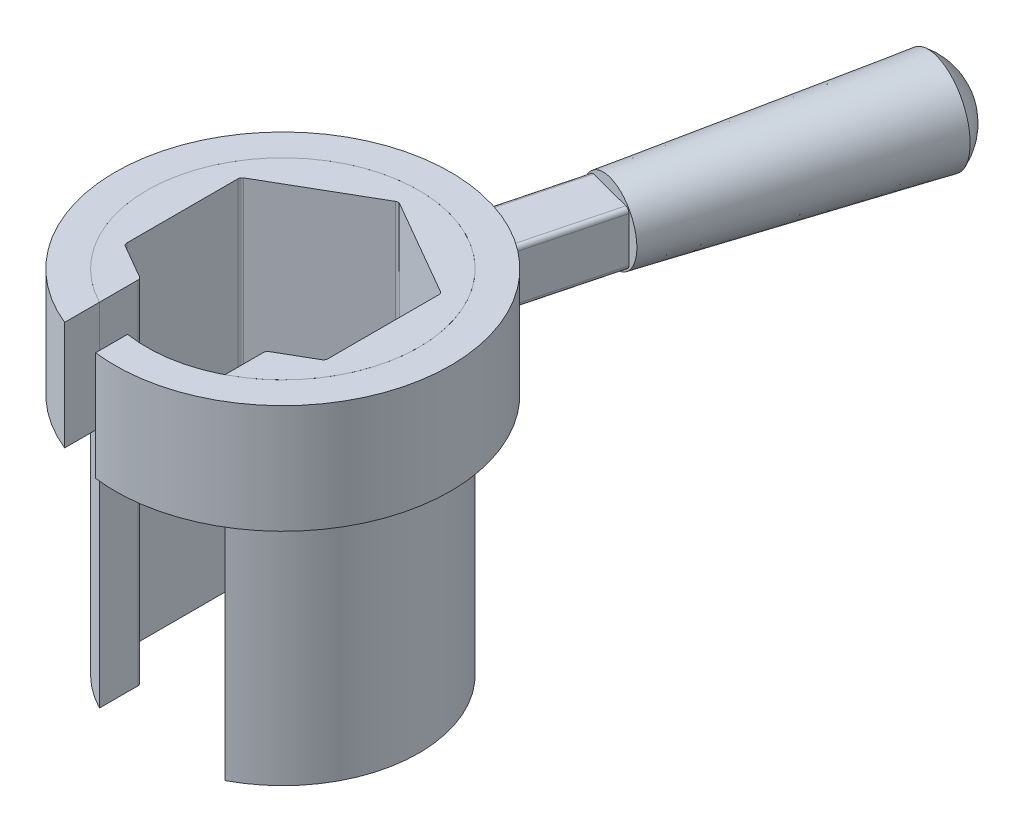
from build123d import *

# Parameters (mm, degrees)
EXTRUDE3_DEPTH                  = 42
EXTRUDE4_DEPTH                  = 13
SKETCH22_W                      = 6.4
SKETCH22_H                      = 6.4
EXTRUDE5_DEPTH                  = 12
EXTRUDE5_DIRECTION_2_REACH      = 64.818
EXTRUDE5_DIRECTION_2_END_RADIUS = 20.03
SKETCH23_R                      = 4.5254834
EXTRUDE6_DEPTH                  = 32
EXTRUDE6_DRAFT                  = -2
DOME1_FACE_RADIUS               = 5.642948023
DOME1_HEIGHT                    = 3
CUT_EXTRUDE7_DEPTH              = 81.414359668
FILLET2_R                       = 0.5
FILLET3_R                       = 0.5


with BuildPart() as part:
    # Sketch20 → Extrude3 (new body)
    with BuildSketch(Plane(origin=(0, 0, 0), x_dir=(1, 0, 0), z_dir=(0, 1, 0))):
        with BuildLine():
            Line((-7.5, -9.367496998), (-7.5, -14.415703243))
            ThreePointArc((-7.5, -14.415703243), (0, 16.25), (7.5, -14.415703243))
            Line((7.5, -14.415703243), (7.5, -9.367496998))
            ThreePointArc((7.5, -9.367496998), (0, 12), (-7.5, -9.367496998))
        make_face()
    extrude(amount=EXTRUDE3_DEPTH)

    # Sketch24 → Cut-Extrude7 (cut, through all)
    with BuildSketch(Plane.XZ):
        Polygon((-12, 6.92820323), (-12, -6.92820323), (0, -13.856406461), (12, -6.92820323), (12, 6.92820323), (0, 13.856406461), align=None)
    extrude(amount=-CUT_EXTRUDE7_DEPTH, mode=Mode.SUBTRACT)

    # Fillet3
    fillet3_edges = [part.edges().sort_by_distance(p)[0] for p in [
        (-7.5, 21, 9.526279442),
        (-12, 21, 6.92820323),
        (7.5, 21, 9.526279442),
        (12, 21, 6.92820323),
        (12, 21, -6.92820323),
        (0, 21, -13.856406461),
        (-12, 21, -6.92820323),
    ]]
    fillet(fillet3_edges, radius=FILLET3_R)


with BuildPart() as body_2:
    # Sketch21 → Extrude4 (new body)
    with BuildSketch(Plane(origin=(0, 41.999, 0), x_dir=(-1, 0, 0), z_dir=(0, 1, 0))):
        with BuildLine():
            Line((2.5, 16.056540723), (2.5, 19.873371631))
            ThreePointArc((2.5, 19.873371631), (-5.042106368, -19.384995831), (7.5, 18.572853846))
            Line((7.5, 18.572853846), (7.5, 14.415703243))
            ThreePointArc((7.5, 14.415703243), (-5.066861643, -15.439864413), (2.5, 16.056540723))
        make_face()
    extrude(amount=-EXTRUDE4_DEPTH)


with BuildPart() as body_3:
    # Sketch22 → Extrude5 (new body)
    with BuildSketch(Plane(origin=(5.042106368, 41.999, -19.384995831), x_dir=(-0.9677980944146168, 0, -0.2517277268149784), z_dir=(0.2517277268149784, 0, -0.9677980944146168))):
        with Locations((0, -6.5)):
            Rectangle(SKETCH22_W, SKETCH22_H)
    extrude(amount=EXTRUDE5_DEPTH)

    # Extrude5 direction 2: up to this cylinder (the profile starts outside it)
    extrude5_direction_2_end = Plane(origin=(0, 35.499, 0), z_dir=(0, 1, 0)) * Cylinder(EXTRUDE5_DIRECTION_2_END_RADIUS, 170.696, mode=Mode.PRIVATE)
    # Sketch22 → Extrude5 direction 2 (add, up to the surface)
    with BuildSketch(Plane(origin=(5.042106368, 41.999, -19.384995831), x_dir=(-0.9677980944146168, 0, -0.2517277268149784), z_dir=(0.2517277268149784, 0, -0.9677980944146168)), mode=Mode.PRIVATE) as extrude5_direction_2_sk1:
        with Locations((0, -6.5)):
            Rectangle(SKETCH22_W, SKETCH22_H)
    extrude5_direction_2_tool1 = extrude(extrude5_direction_2_sk1.sketch, amount=-EXTRUDE5_DIRECTION_2_REACH, mode=Mode.PRIVATE) - extrude5_direction_2_end
    add(extrude5_direction_2_tool1.solids().sort_by_distance((5.042106, 35.499, -19.384996))[0])
    add(extrude5_direction_2_tool1.solids().sort_by_distance((5.042106, 35.499, -19.384996))[1])


with BuildPart() as extrude6_tool:
    # Sketch23 → Extrude6 (with draft: the straight prism first)
    with BuildSketch(Plane(origin=(8.06283909, 0, -30.998572964), x_dir=(-0.9677980944146167, -1.6827536930173812e-15, -0.25172772681497885), z_dir=(0.25172772681497885, 0, -0.9677980944146167))):
        with Locations((0, 35.499)):
            Circle(SKETCH23_R)
    extrude(amount=EXTRUDE6_DEPTH)
    # Extrude6: the draft: its side faces are tilted about the plane it starts from
    extrude6_sides = [extrude6_tool.faces().sort_by_distance(p)[0] for p in [
        (16.470236929, 35.499, -45.344152826),
    ]]
    draft(extrude6_sides, Plane(origin=(8.06283909, 0, -30.998572964), x_dir=(-0.9677980944146167, -1.6827536930173812e-15, -0.25172772681497885), z_dir=(0.25172772681497885, 0, -0.9677980944146167)), EXTRUDE6_DRAFT)


with BuildPart() as body_3_1:
    add(body_3.part)

    # Extrude6: add extrude6_tool
    add(extrude6_tool.part)

    # Dome1: a dome of height H over a round flat face of radius A is a cap of a sphere of radius (A * A + H * H) / (2 * H)
    dome1_r = (DOME1_FACE_RADIUS * DOME1_FACE_RADIUS + DOME1_HEIGHT * DOME1_HEIGHT) / (2 * DOME1_HEIGHT)
    dome1_base = Plane((16.118126348, 35.499, -61.968111985), z_dir=(0.251727726815, 0, -0.967798094415))
    with Locations(dome1_base.offset(DOME1_HEIGHT - dome1_r)):
        dome1_ball = Sphere(dome1_r, mode=Mode.PRIVATE)
    add(split(dome1_ball, bisect_by=dome1_base, keep=Keep.TOP, mode=Mode.PRIVATE))

    # Fillet2
    fillet2_edges = [body_3_1.edges().sort_by_distance(p)[0] for p in [
        (9.617045789, 38.699, -24.261763556),
        (3.423137985, 38.699, -25.872821007),
        (3.423137985, 32.299, -25.872821007),
        (9.617045789, 32.299, -24.261763556),
    ]]
    fillet(fillet2_edges, radius=FILLET2_R)


solid = Compound([part.part, body_2.part, body_3_1.part])
